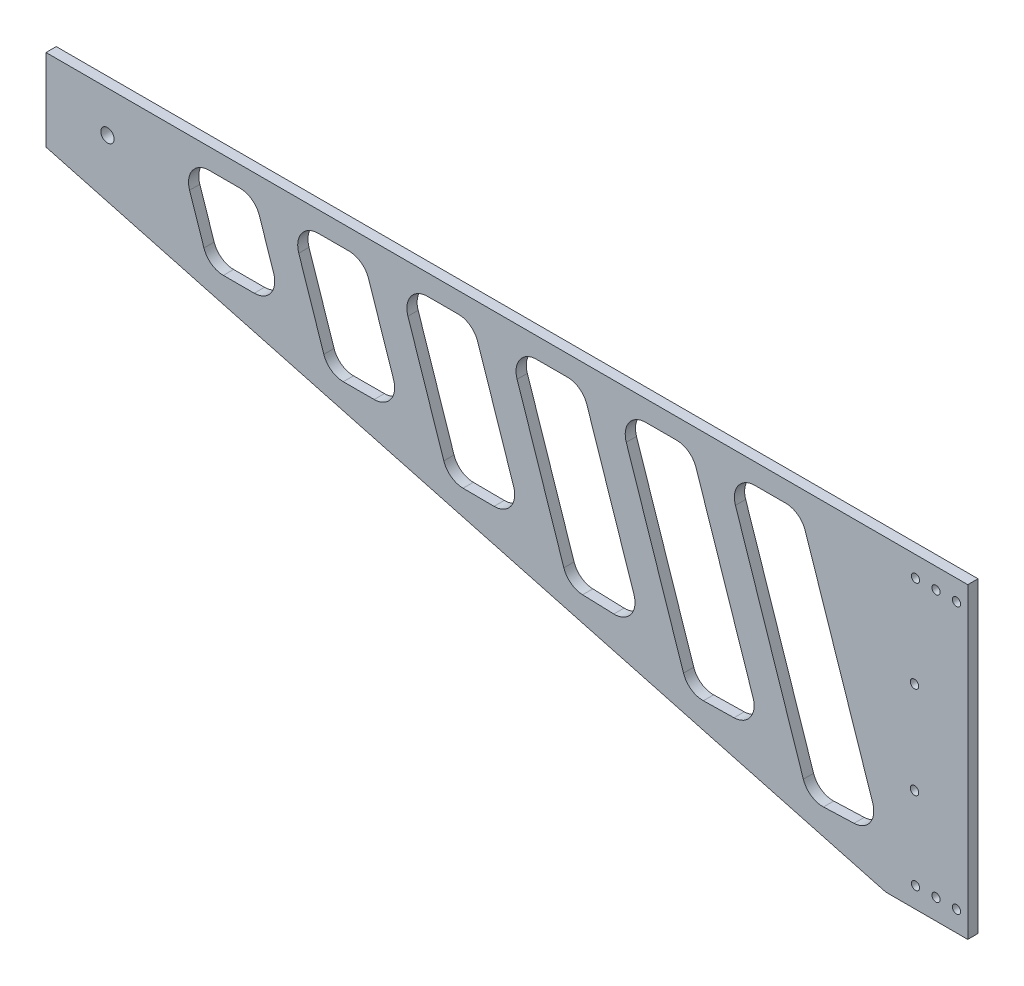
from build123d import *

# Parameters (mm, degrees)
AUFSATZ_LINEAR_AUSTRAGEN1_DEPTH  = 5
SKIZZE2_R                        = 3.25
SCHNITT_LINEAR_AUSTRAGEN1_DEPTH  = 6
F_4_0_4_DURCHMESSER_BOHRUNG1_D   = 4
F_4_1_4_1_DURCHMESSER_BOHRUNG1_D = 4.1
SCHNITT_LINEAR_AUSTRAGEN2_DEPTH  = 8


with BuildPart() as part:
    # Skizze1 → Aufsatz-Linear austragen1 (new body)
    with BuildSketch(Plane.XY):
        Polygon((0, 0), (0, -150), (-40, -150), (-450, -40), (-450, 0), align=None)
    extrude(amount=AUFSATZ_LINEAR_AUSTRAGEN1_DEPTH)

    # Skizze2 → Schnitt-Linear austragen1 (cut, through all)
    with BuildSketch(Plane.XY.offset(5)):
        with Locations((-420, -20)):
            Circle(SKIZZE2_R)
    extrude(amount=-SCHNITT_LINEAR_AUSTRAGEN1_DEPTH, mode=Mode.SUBTRACT)

    # Ø4.0 (4) Durchmesser Bohrung1 (through all)
    with Locations(Plane.XY.offset(5)):
        with Locations((-25.5, -10), (-15.5, -10), (-5.5, -10), (-5.5, -140), (-15.5, -140), (-25.5, -140)):
            Hole(F_4_0_4_DURCHMESSER_BOHRUNG1_D / 2)

    # Ø4.1 (4.1) Durchmesser Bohrung1 (through all)
    with Locations(Plane(origin=(0, 0, 0), x_dir=(-1, 0, 0), z_dir=(0, 0, -1))):
        with Locations((26, -55), (26, -100)):
            Hole(F_4_1_4_1_DURCHMESSER_BOHRUNG1_D / 2)

    # Skizze9 → Schnitt-Linear austragen2 (cut)
    with BuildSketch(Plane.XY.offset(5)):
        with BuildLine():
            Line((-103.931576355, -10), (-88.847327603, -10))
            ThreePointArc((-88.847327603, -10), (-83.003068108, -11.885529533), (-79.362713389, -16.831073809))
            Line((-79.362713389, -16.831073809), (-67.965211215, -50.943863007))
            Line((-67.965211215, -50.943863007), (-46.397909384, -115.49492075))
            ThreePointArc((-46.397909384, -115.49492075), (-47.662174175, -124.358217438), (-55.515574608, -128.657112095))
            Line((-55.515574608, -128.657112095), (-70.41700546, -129.20428711))
            ThreePointArc((-70.41700546, -129.20428711), (-76.478324948, -127.43137138), (-80.268568666, -122.379948147))
            Line((-80.268568666, -122.379948147), (-104.136242779, -50.943863007))
            Line((-104.136242779, -50.943863007), (-113.416190569, -23.168926191))
            ThreePointArc((-113.416190569, -23.168926191), (-112.046046821, -14.155740505), (-103.931576355, -10))
        make_face()
        with BuildLine():
            Line((-132.659135945, -16.831073809), (-121.261633772, -50.943863007))
            Line((-121.261633772, -50.943863007), (-104.819891238, -100.154092454))
            ThreePointArc((-104.819891238, -100.154092454), (-106.1314685, -109.085090058), (-114.102677631, -113.320981714))
            Line((-114.102677631, -113.320981714), (-129.085869406, -113.62344582))
            ThreePointArc((-129.085869406, -113.62344582), (-135.049768642, -111.798519703), (-138.772311443, -106.794408942))
            Line((-138.772311443, -106.794408942), (-157.432665335, -50.943863007))
            Line((-157.432665335, -50.943863007), (-166.712613125, -23.168926191))
            ThreePointArc((-166.712613125, -23.168926191), (-165.342469378, -14.155740505), (-157.227998911, -10))
            Line((-157.227998911, -10), (-142.14375016, -10))
            ThreePointArc((-142.14375016, -10), (-136.299490665, -11.885529533), (-132.659135945, -16.831073809))
        make_face()
        with BuildLine():
            Line((-185.955558502, -16.831073809), (-174.558056328, -50.943863007))
            Line((-174.558056328, -50.943863007), (-162.967615916, -85.634117455))
            ThreePointArc((-162.967615916, -85.634117455), (-164.435252335, -94.780339607), (-172.782043853, -98.797603311))
            Line((-172.782043853, -98.797603311), (-188.034457791, -98.294283947))
            ThreePointArc((-188.034457791, -98.294283947), (-193.68194003, -96.316702077), (-197.189258283, -91.468650472))
            Line((-197.189258283, -91.468650472), (-210.729087892, -50.943863007))
            Line((-210.729087892, -50.943863007), (-220.009035682, -23.168926191))
            ThreePointArc((-220.009035682, -23.168926191), (-218.638891934, -14.155740505), (-210.524421467, -10))
            Line((-210.524421467, -10), (-195.440172716, -10))
            ThreePointArc((-195.440172716, -10), (-189.595913221, -11.885529533), (-185.955558502, -16.831073809))
        make_face()
        with BuildLine():
            Line((-239.251981058, -16.831073809), (-227.854478884, -50.943863007))
            Line((-227.854478884, -50.943863007), (-221.703520719, -69.353715979))
            ThreePointArc((-221.703520719, -69.353715979), (-223.095303096, -78.396829164), (-231.261995944, -82.522369394))
            Line((-231.261995944, -82.522369394), (-246.383562521, -82.410676928))
            ThreePointArc((-246.383562521, -82.410676928), (-252.183888505, -80.503781541), (-255.794315725, -75.579875894))
            Line((-255.794315725, -75.579875894), (-264.025510448, -50.943863007))
            Line((-264.025510448, -50.943863007), (-273.305458238, -23.168926191))
            ThreePointArc((-273.305458238, -23.168926191), (-271.93531449, -14.155740505), (-263.820844024, -10))
            Line((-263.820844024, -10), (-248.736595273, -10))
            ThreePointArc((-248.736595273, -10), (-242.892335777, -11.885529533), (-239.251981058, -16.831073809))
        make_face()
        with BuildLine():
            Line((-292.548403615, -16.831073809), (-281.150901441, -50.943863007))
            Line((-281.150901441, -50.943863007), (-280.31760719, -53.437917466))
            ThreePointArc((-280.31760719, -53.437917466), (-281.68198, -62.443082132), (-289.782458776, -66.606824129))
            Line((-289.782458776, -66.606824129), (-304.856754045, -66.636614958))
            ThreePointArc((-304.856754045, -66.636614958), (-310.712755148, -64.75687589), (-314.361130888, -59.805560676))
            Line((-314.361130888, -59.805560676), (-317.321933004, -50.943863007))
            Line((-317.321933004, -50.943863007), (-326.601880795, -23.168926191))
            ThreePointArc((-326.601880795, -23.168926191), (-325.231737047, -14.155740505), (-317.11726658, -10))
            Line((-317.11726658, -10), (-302.033017829, -10))
            ThreePointArc((-302.033017829, -10), (-296.188758334, -11.885529533), (-292.548403615, -16.831073809))
        make_face()
        with BuildLine():
            Line((-345.844826171, -16.831073809), (-338.847224106, -37.774936817))
            ThreePointArc((-338.847224106, -37.774936817), (-340.217367853, -46.788122502), (-348.33183832, -50.943863007))
            Line((-348.33183832, -50.943863007), (-363.416087071, -50.943863007))
            ThreePointArc((-363.416087071, -50.943863007), (-369.260346566, -49.058333474), (-372.900701286, -44.112789198))
            Line((-372.900701286, -44.112789198), (-379.898303351, -23.168926191))
            ThreePointArc((-379.898303351, -23.168926191), (-378.528159603, -14.155740505), (-370.413689137, -10))
            Line((-370.413689137, -10), (-355.329440386, -10))
            ThreePointArc((-355.329440386, -10), (-349.48518089, -11.885529533), (-345.844826171, -16.831073809))
        make_face()
    extrude(amount=-SCHNITT_LINEAR_AUSTRAGEN2_DEPTH, mode=Mode.SUBTRACT)


solid = part.part
